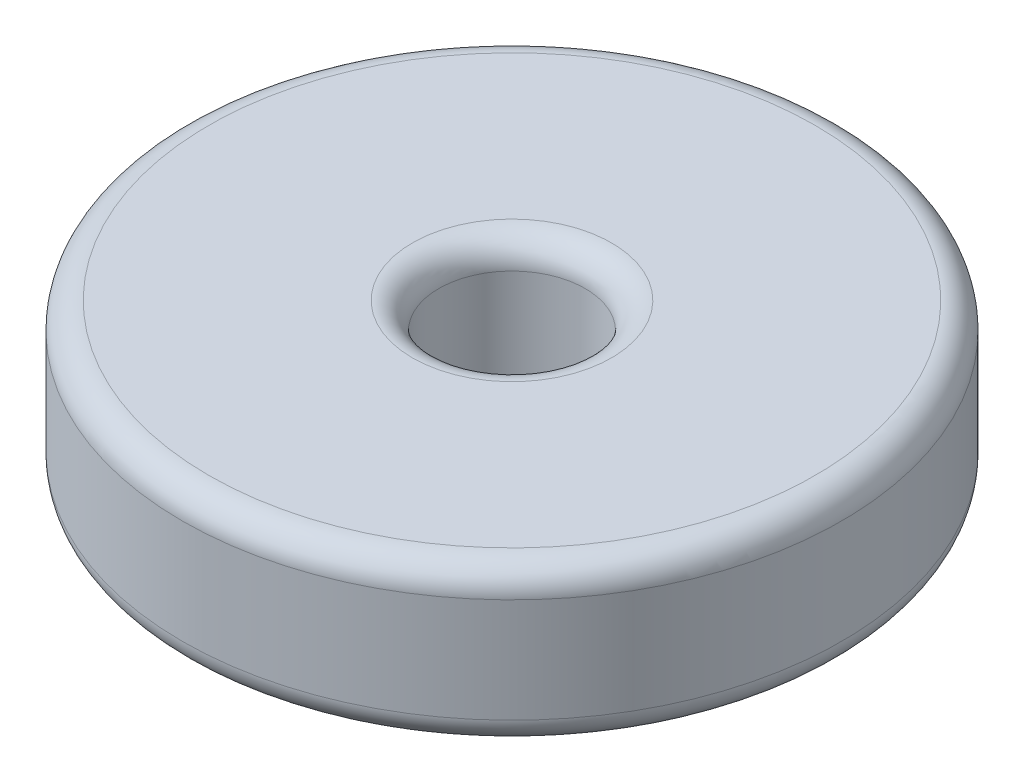
from build123d import *

# Parameters (mm, degrees)
SKETCH1_R           = 12.5
BOSS_EXTRUDE1_DEPTH = 5.953125
SKETCH2_R           = 2.7781
CUT_EXTRUDE1_DEPTH  = 5.953125
FILLET1_R           = 1


with BuildPart() as part:
    # Sketch1 → Boss-Extrude1 (new body)
    with BuildSketch(Plane(origin=(0, 0, 0), x_dir=(1, 0, 0), z_dir=(0, 1, 0))):
        Circle(SKETCH1_R)
    extrude(amount=BOSS_EXTRUDE1_DEPTH)

    # Sketch2 → Cut-Extrude1 (cut)
    with BuildSketch(Plane(origin=(0, 5.953125, 0), x_dir=(1, 0, 0), z_dir=(0, 1, 0))):
        Circle(SKETCH2_R)
    extrude(amount=-CUT_EXTRUDE1_DEPTH, mode=Mode.SUBTRACT)

    # Fillet1
    fillet1_edges = [part.edges().sort_by_distance(p)[0] for p in [
        (-12.5, 0, 0),
        (-12.5, 5.953125, 0),
        (-2.7781, 5.953125, 0),
        (-2.7781, 0, 0),
    ]]
    fillet(fillet1_edges, radius=FILLET1_R)


solid = part.part
